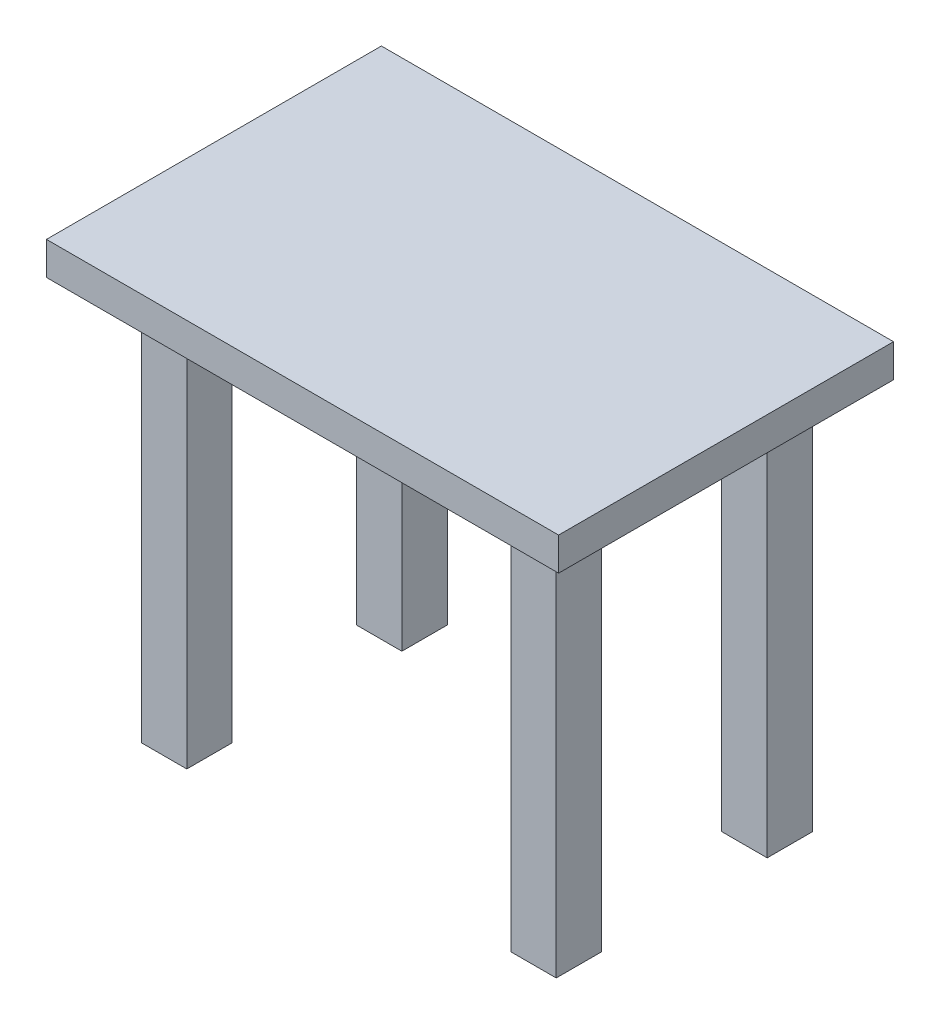
from build123d import *

# Parameters (mm, degrees)
SKETCH1_W           = 155.20995072
SKETCH1_H           = 101.500935516
BOSS_EXTRUDE1_DEPTH = 10
SKETCH2_W           = 13.766131438
SKETCH2_H           = 13.766131439
SKETCH2_H_2         = 13.766131438
SKETCH2_W_2         = 13.766131439
BOSS_EXTRUDE2_DEPTH = 130


with BuildPart() as part:
    # Sketch1 → Boss-Extrude1 (new body)
    with BuildSketch(Plane(origin=(0, 0, 0), x_dir=(1, 0, 0), z_dir=(0, 1, 0))):
        Rectangle(SKETCH1_W, SKETCH1_H)
    extrude(amount=-BOSS_EXTRUDE1_DEPTH)

    # Sketch2 → Boss-Extrude2 (add)
    with BuildSketch(Plane(origin=(0, 0, 0), x_dir=(1, 0, 0), z_dir=(0, 1, 0))):
        with Locations((57.048171322, 33.010928537)):
            Rectangle(SKETCH2_W, SKETCH2_H)
        with Locations((-52.536052633, 31.886855475)):
            Rectangle(SKETCH2_W, SKETCH2_H_2)
        with Locations((-54.221701381, -31.605914017)):
            Rectangle(SKETCH2_W_2, SKETCH2_H_2)
        with Locations((56.609703773, -30.482148186)):
            Rectangle(SKETCH2_W, SKETCH2_H)
    extrude(amount=-BOSS_EXTRUDE2_DEPTH)


solid = part.part
